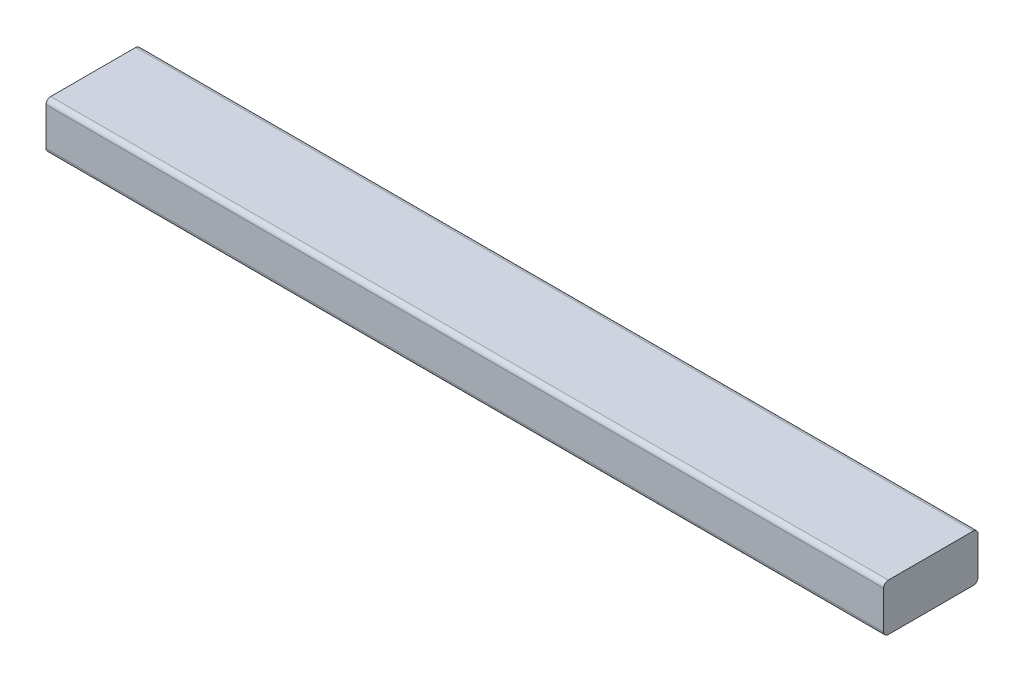
from build123d import *

# Parameters (mm, degrees)
SKETCH1_W           = 901.6
SKETCH1_H           = 101.6
BOSS_EXTRUDE1_DEPTH = 50.8
FILLET1_R           = 5.08


with BuildPart() as part:
    # Sketch1 → Boss-Extrude1 (new body)
    with BuildSketch(Plane(origin=(0, -12.7, 0), x_dir=(-1, 0, 0), z_dir=(0, -1, 0))):
        with Locations((-2263.5, 338.5)):
            Rectangle(SKETCH1_W, SKETCH1_H)
    extrude(amount=-BOSS_EXTRUDE1_DEPTH)

    # Fillet1
    fillet1_edges = [part.edges().sort_by_distance(p)[0] for p in [
        (2263.5, 38.1, -389.3),
        (2263.5, -12.7, -389.3),
        (2263.5, -12.7, -287.7),
        (2263.5, 38.1, -287.7),
    ]]
    fillet(fillet1_edges, radius=FILLET1_R)


solid = part.part
